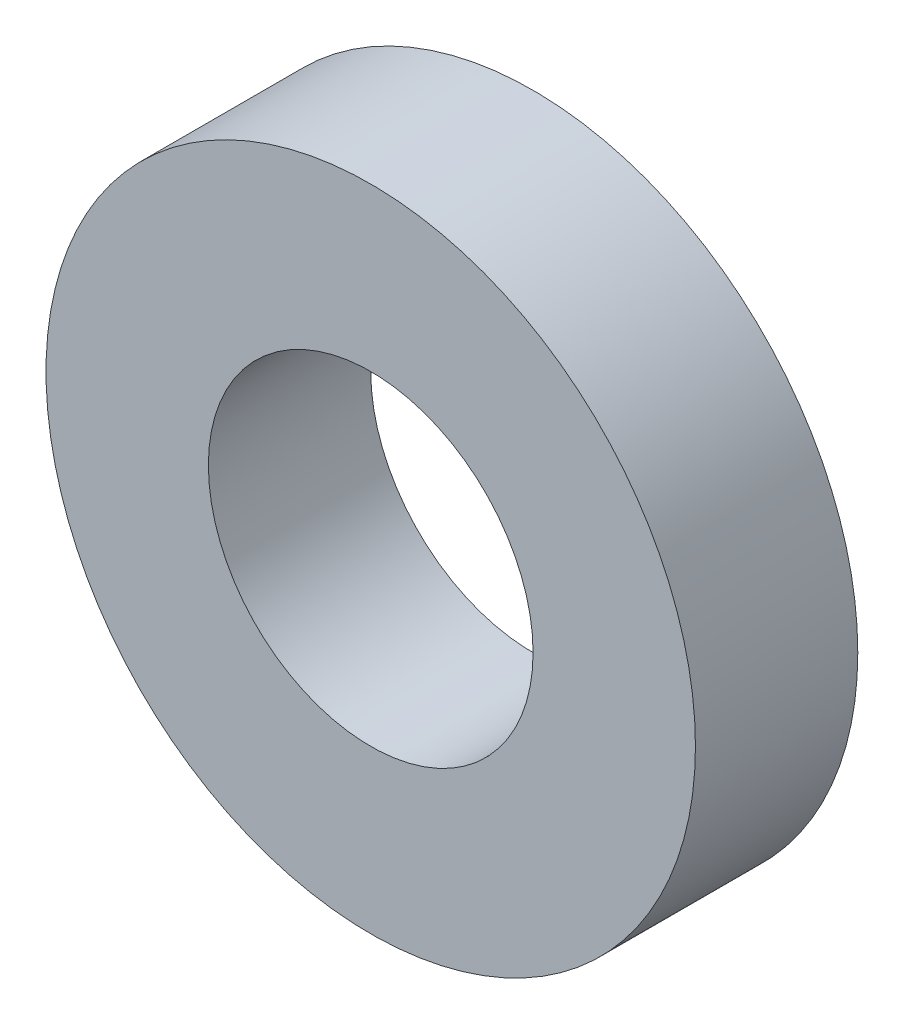
from build123d import *

# Parameters (mm, degrees)
SKETCH_2_R      = 6
SKETCH_2_R_2    = 3
EXTRUDE_1_DEPTH = 3


with BuildPart() as part:
    # 草图2 → 凸台-拉伸1 (new body)
    with BuildSketch(Plane.XY):
        Circle(SKETCH_2_R)
        Circle(SKETCH_2_R_2, mode=Mode.SUBTRACT)
    extrude(amount=EXTRUDE_1_DEPTH)


solid = part.part
